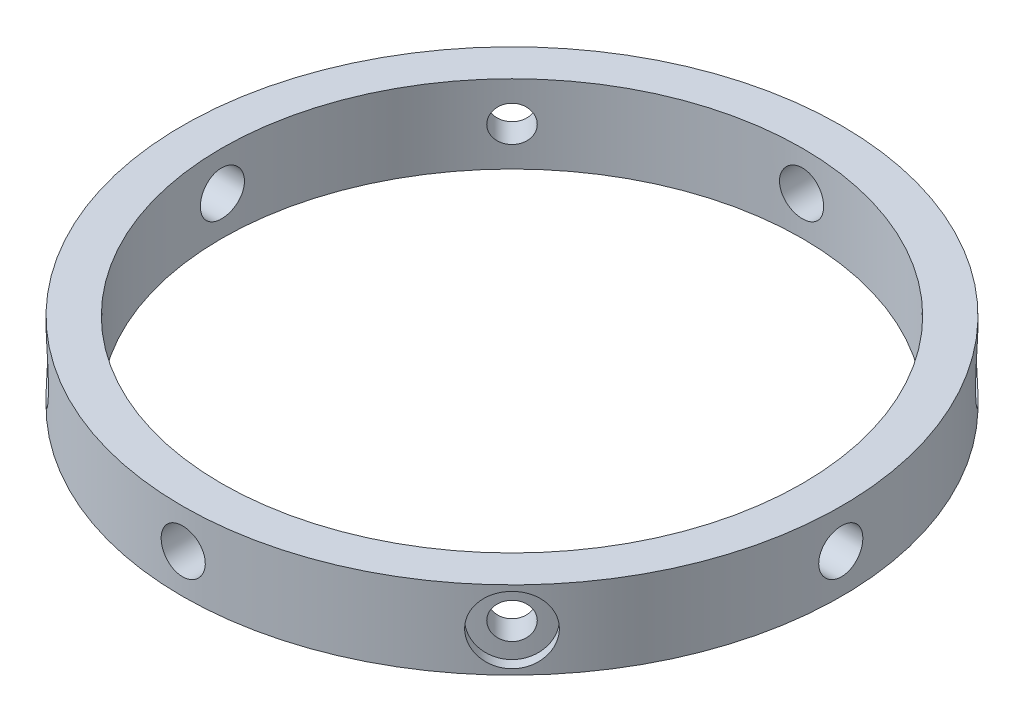
from build123d import *

# Parameters (mm, degrees)
SKETCH1_R                = 29.5
SKETCH1_R_2              = 26
BOSS_EXTRUDE1_DEPTH      = 3.5
BOSS_EXTRUDE1_DEPTH_BACK = 3.5
SKETCH3_R                = 1.975
CUT_EXTRUDE1_DEPTH       = 42.865857211
CUT_EXTRUDE1_DEPTH_BACK  = 42.865857211
SKETCH4_R                = 1.975
CUT_EXTRUDE2_DEPTH       = 42.865857362
CUT_EXTRUDE2_DEPTH_BACK  = 42.865857362
SKETCH5_R                = 1.6
CUT_EXTRUDE3_DEPTH       = 42.865857364
CUT_EXTRUDE3_DEPTH_BACK  = 42.865857364
SKETCH6_R                = 1.6
CUT_EXTRUDE4_DEPTH       = 42.865857364
CUT_EXTRUDE4_DEPTH_BACK  = 42.865857364
CUT_EXTRUDE5_REACH       = 73.305
CUT_EXTRUDE5_END_RADIUS  = 28.5
SKETCH7_R                = 3
CIRPATTERN1_COUNT        = 4


with BuildPart() as part:
    # Sketch1 → Boss-Extrude1 (new, two sides)
    with BuildSketch(Plane(origin=(0, 0, 0), x_dir=(1, 0, 0), z_dir=(0, 1, 0))) as boss_extrude1_sk:
        with Locations(Location((0, 0, 0), (0, 0, 270))):
            Circle(SKETCH1_R)
        with Locations(Location((0, 0, 0), (0, 0, 270))):
            Circle(SKETCH1_R_2, mode=Mode.SUBTRACT)
    extrude(amount=BOSS_EXTRUDE1_DEPTH)
    extrude(boss_extrude1_sk.sketch, amount=-BOSS_EXTRUDE1_DEPTH_BACK)

    # Sketch3 → Cut-Extrude1 (cut, two sides)
    with BuildSketch(Plane(origin=(0, 0, 0), x_dir=(0, 0, -1), z_dir=(1, 0, 0))) as cut_extrude1_sk:
        Circle(SKETCH3_R)
    extrude(amount=CUT_EXTRUDE1_DEPTH, mode=Mode.SUBTRACT)
    extrude(cut_extrude1_sk.sketch, amount=-CUT_EXTRUDE1_DEPTH_BACK, mode=Mode.SUBTRACT)

    # Sketch4 → Cut-Extrude2 (cut, two sides)
    with BuildSketch(Plane.XY) as cut_extrude2_sk:
        Circle(SKETCH4_R)
    extrude(amount=CUT_EXTRUDE2_DEPTH, mode=Mode.SUBTRACT)
    extrude(cut_extrude2_sk.sketch, amount=-CUT_EXTRUDE2_DEPTH_BACK, mode=Mode.SUBTRACT)

    # Sketch5 → Cut-Extrude3 (cut, two sides)
    with BuildSketch(Plane(origin=(0, 0, 0), x_dir=(-0.7071067811865477, 0, -0.7071067811865475), z_dir=(0.7071067811865475, 0, -0.7071067811865477))) as cut_extrude3_sk:
        Circle(SKETCH5_R)
    extrude(amount=CUT_EXTRUDE3_DEPTH, mode=Mode.SUBTRACT)
    extrude(cut_extrude3_sk.sketch, amount=-CUT_EXTRUDE3_DEPTH_BACK, mode=Mode.SUBTRACT)

    # Sketch6 → Cut-Extrude4 (cut, two sides)
    with BuildSketch(Plane(origin=(0, 0, 0), x_dir=(0.7071067811865476, 0, -0.7071067811865476), z_dir=(0.7071067811865476, 0, 0.7071067811865476))) as cut_extrude4_sk:
        Circle(SKETCH6_R)
    extrude(amount=CUT_EXTRUDE4_DEPTH, mode=Mode.SUBTRACT)
    extrude(cut_extrude4_sk.sketch, amount=-CUT_EXTRUDE4_DEPTH_BACK, mode=Mode.SUBTRACT)

    # Cut-Extrude5: up to this cylinder (the profile starts outside it)
    cut_extrude5_end = Plane(origin=(0, 0, 0), z_dir=(0, 1, 0)) * Cylinder(CUT_EXTRUDE5_END_RADIUS, 204.61, mode=Mode.PRIVATE)
    # Sketch7 → Cut-Extrude5 (cut, up to the surface)
    with BuildSketch(Plane(origin=(20.859650045, 0, 20.859650045), x_dir=(0.7071067811865475, 0, -0.7071067811865477), z_dir=(0.7071067811865477, 0, 0.7071067811865475)), mode=Mode.PRIVATE) as cut_extrude5_sk1:
        Circle(SKETCH7_R)
    cut_extrude5_tool1 = extrude(cut_extrude5_sk1.sketch, amount=-CUT_EXTRUDE5_REACH, mode=Mode.PRIVATE) - cut_extrude5_end
    cut_extrude5 = cut_extrude5_tool1.solids().sort_by_distance((20.85965, 0, 20.85965))[0]
    add(cut_extrude5, mode=Mode.SUBTRACT)

    # CirPattern1: Cut-Extrude5 ×4 about axis
    cirpattern1_axis = Axis((0, 0, 0), (0, 1, 0))
    for i in range(1, CIRPATTERN1_COUNT):
        add(cut_extrude5.rotate(cirpattern1_axis, i * 360 / CIRPATTERN1_COUNT), mode=Mode.SUBTRACT)


solid = part.part
